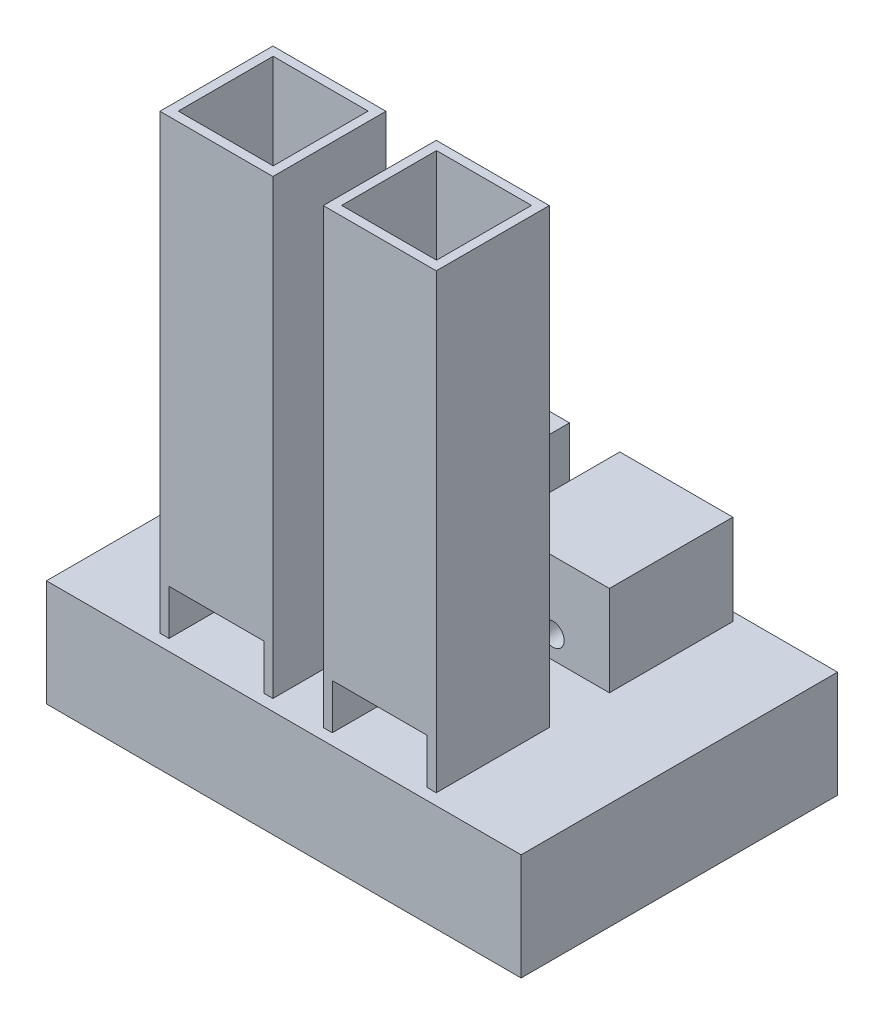
from build123d import *

# Parameters (mm, degrees)
SKETCH1_W           = 266.7
SKETCH1_H           = 177.8
BOSS_EXTRUDE1_DEPTH = 59.944
SKETCH2_W           = 63.5
SKETCH2_H           = 63.5
SKETCH2_W_2         = 53.34
SKETCH2_H_2         = 53.34
BOSS_EXTRUDE2_DEPTH = 254
SKETCH3_W           = 53.34
SKETCH3_H           = 25.4
CUT_EXTRUDE1_DEPTH  = 254
SKETCH4_W           = 63.5
SKETCH4_H           = 69.373154479
BOSS_EXTRUDE3_DEPTH = 50.8
SKETCH5_R           = 6.35
CUT_EXTRUDE2_DEPTH  = 50.8


with BuildPart() as part:
    # Sketch1 → Boss-Extrude1 (new body)
    with BuildSketch(Plane(origin=(0, 0, 0), x_dir=(1, 0, 0), z_dir=(0, 1, 0))):
        with Locations((133.35, 88.9)):
            Rectangle(SKETCH1_W, SKETCH1_H)
    extrude(amount=BOSS_EXTRUDE1_DEPTH)

    # Sketch2 → Boss-Extrude2 (add)
    with BuildSketch(Plane(origin=(0, 59.944, 0), x_dir=(1, 0, 0), z_dir=(0, 1, 0))):
        with Locations((180.927983049, 38.1)):
            Rectangle(SKETCH2_W, SKETCH2_H)
        with Locations((180.927983049, 38.260329554)):
            Rectangle(SKETCH2_W_2, SKETCH2_H_2, mode=Mode.SUBTRACT)
        with Locations((89.140378802, 38.1)):
            Rectangle(SKETCH2_W, SKETCH2_H)
        with Locations((89.140378802, 38.260329554)):
            Rectangle(SKETCH2_W_2, SKETCH2_H_2, mode=Mode.SUBTRACT)
    extrude(amount=BOSS_EXTRUDE2_DEPTH)

    # Sketch3 → Cut-Extrude1 (cut)
    with BuildSketch(Plane.XY.offset(-6.35)):
        with Locations((89.140378802, 72.644)):
            Rectangle(SKETCH3_W, SKETCH3_H)
        with Locations((180.927983049, 72.644)):
            Rectangle(SKETCH3_W, SKETCH3_H)
    extrude(amount=-CUT_EXTRUDE1_DEPTH, mode=Mode.SUBTRACT)

    # Sketch4 → Boss-Extrude3 (add)
    with BuildSketch(Plane(origin=(0, 59.944, 0), x_dir=(1, 0, 0), z_dir=(0, 1, 0))):
        with Locations((89.140378802, 138.306511279)):
            Rectangle(SKETCH4_W, SKETCH4_H)
        with Locations((180.927983049, 138.306511279)):
            Rectangle(SKETCH4_W, SKETCH4_H)
    extrude(amount=BOSS_EXTRUDE3_DEPTH)

    # Sketch5 → Cut-Extrude2 (cut)
    with BuildSketch(Plane.XY.offset(-103.619934039)):
        with Locations((180.927983049, 72.644)):
            Circle(SKETCH5_R)
        with Locations((89.140378802, 72.644)):
            Circle(SKETCH5_R)
    extrude(amount=-CUT_EXTRUDE2_DEPTH, mode=Mode.SUBTRACT)


solid = part.part
